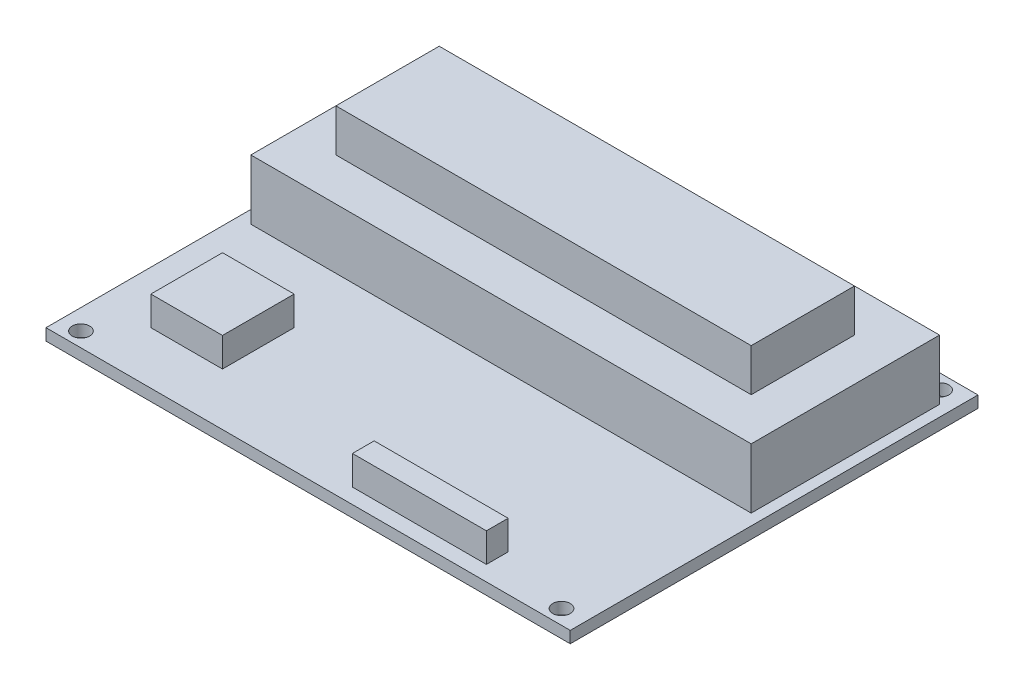
from build123d import *

# Parameters (mm, degrees)
SKETCH1_W           = 90
SKETCH1_H           = 70
BOSS_EXTRUDE1_DEPTH = 2
SKETCH2_R           = 1.5
CUT_EXTRUDE1_DEPTH  = 3
SKETCH3_W           = 23
SKETCH3_H           = 3.733741838
SKETCH3_W_2         = 12.3
SKETCH3_H_2         = 12.3
BOSS_EXTRUDE2_DEPTH = 5
SKETCH4_W           = 71.3
SKETCH4_H           = 17.735180651
BOSS_EXTRUDE3_DEPTH = 17.6
SKETCH5_W           = 85.9
SKETCH5_H           = 32.335180651
BOSS_EXTRUDE4_DEPTH = 10.3


with BuildPart() as part:
    # Sketch1 → Boss-Extrude1 (new body)
    with BuildSketch(Plane(origin=(0, 0, 0), x_dir=(1, 0, 0), z_dir=(0, 1, 0))):
        Rectangle(SKETCH1_W, SKETCH1_H)
    extrude(amount=BOSS_EXTRUDE1_DEPTH)

    # Sketch2 → Cut-Extrude1 (cut, through all)
    with BuildSketch(Plane(origin=(0, 2, 0), x_dir=(1, 0, 0), z_dir=(0, 1, 0))):
        with Locations((-41.5, 32.5)):
            Circle(SKETCH2_R)
        with Locations((-41.5, -32.5)):
            Circle(SKETCH2_R)
        with Locations((41, -32.5)):
            Circle(SKETCH2_R)
        with Locations((41, 32.5)):
            Circle(SKETCH2_R)
    extrude(amount=-CUT_EXTRUDE1_DEPTH, mode=Mode.SUBTRACT)

    # Sketch3 → Boss-Extrude2 (add)
    with BuildSketch(Plane(origin=(0, 2, 0), x_dir=(1, 0, 0), z_dir=(0, 1, 0))):
        with Locations((16.5, -30.528214904)):
            Rectangle(SKETCH3_W, SKETCH3_H)
        with Locations((-29.85, -19.85)):
            Rectangle(SKETCH3_W_2, SKETCH3_H_2)
    extrude(amount=BOSS_EXTRUDE2_DEPTH)

    # Sketch4 → Boss-Extrude3 (add)
    with BuildSketch(Plane(origin=(0, 2, 0), x_dir=(1, 0, 0), z_dir=(0, 1, 0))):
        with Locations((0.15, 14.132409674)):
            Rectangle(SKETCH4_W, SKETCH4_H)
    extrude(amount=BOSS_EXTRUDE3_DEPTH)

    # Sketch5 → Boss-Extrude4 (add)
    with BuildSketch(Plane(origin=(0, 2, 0), x_dir=(1, 0, 0), z_dir=(0, 1, 0))):
        with Locations((0.15, 14.132409674)):
            Rectangle(SKETCH5_W, SKETCH5_H)
    extrude(amount=BOSS_EXTRUDE4_DEPTH)


solid = part.part
